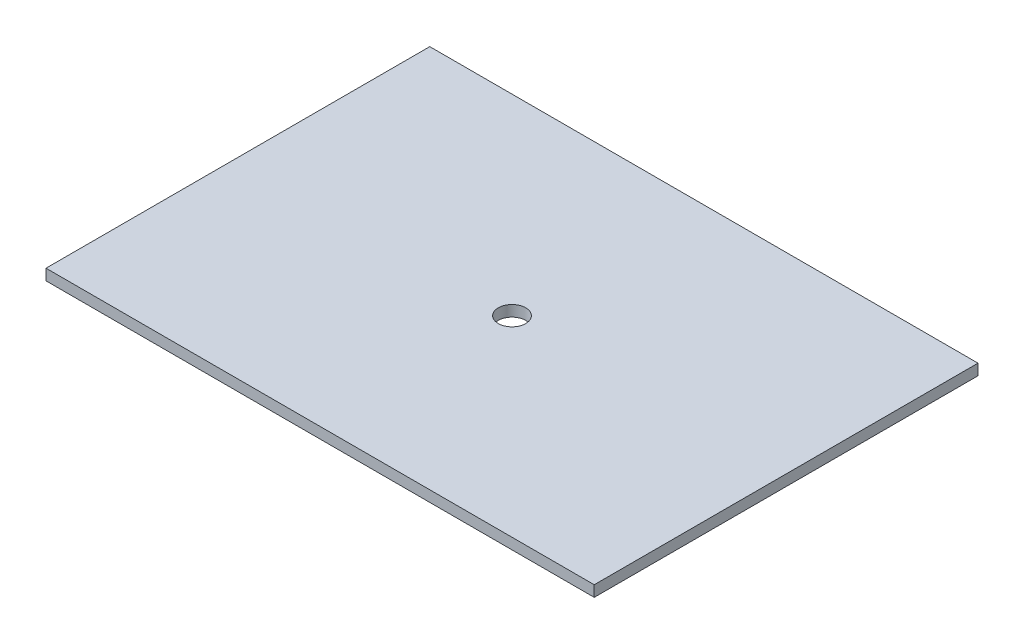
from build123d import *

# Parameters (mm, degrees)
SKETCH1_W           = 127
SKETCH1_H           = 88.9
SKETCH1_R           = 3.175
BOSS_EXTRUDE1_DEPTH = 2.54


with BuildPart() as part:
    # Sketch1 → Boss-Extrude1 (new body)
    with BuildSketch(Plane(origin=(0, 0, 0), x_dir=(1, 0, 0), z_dir=(0, 1, 0))):
        with Locations((-63.5, 44.45)):
            Rectangle(SKETCH1_W, SKETCH1_H)
        with Locations((-63.5, 44.45)):
            Circle(SKETCH1_R, mode=Mode.SUBTRACT)
    extrude(amount=BOSS_EXTRUDE1_DEPTH)


solid = part.part
